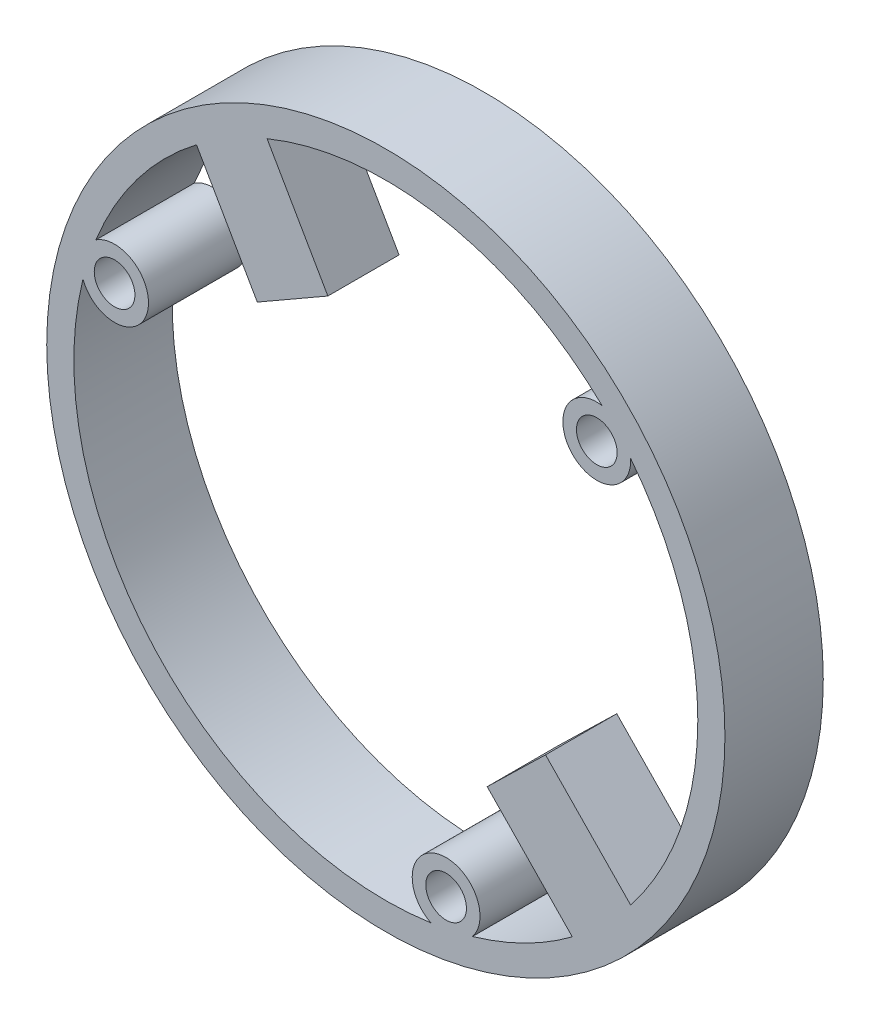
from build123d import *

# Parameters (mm, degrees)
SKETCH1_R             = 25
BOSS_EXTRUDE1_DEPTH   = 7.25
F_3_0MM_DOWEL_HOLE1_D = 3
CIRPATTERN1_COUNT     = 3
CUT_EXTRUDE7_DEPTH    = 8.25
CUT_EXTRUDE9_DEPTH    = 2


with BuildPart() as part:
    # Sketch1 → Boss-Extrude1 (new body)
    with BuildSketch(Plane.XY):
        Circle(SKETCH1_R)
    extrude(amount=BOSS_EXTRUDE1_DEPTH)

    # Ø3.0mm Dowel Hole1 (through all)
    with Locations(Plane(origin=(0, 0, 0), x_dir=(-1, 0, 0), z_dir=(0, 0, -1))):
        with Locations((-15.552844037, 14.110600354)):
            f_3_0mm_dowel_hole1 = Hole(F_3_0MM_DOWEL_HOLE1_D / 2)

    # CirPattern1: Ø3.0mm Dowel Hole1 ×3 about axis
    cirpattern1_axis = Axis((0, 0, 0), (0, 0, 1))
    for i in range(1, CIRPATTERN1_COUNT):
        add(f_3_0mm_dowel_hole1.rotate(cirpattern1_axis, i * 360 / CIRPATTERN1_COUNT), mode=Mode.SUBTRACT)

    # Sketch4 → Cut-Extrude7 (cut, through all)
    with BuildSketch(Plane(origin=(0, 0, 0), x_dir=(-1, 0, 0), z_dir=(0, 0, -1))):
        with BuildLine():
            Line((8.755064083, 21.268494373), (4.272899712, 13.463995507))
            Line((4.272899712, 13.463995507), (9.475898956, 10.475885926))
            Line((9.475898956, 10.475885926), (13.958063327, 18.280384792))
            ThreePointArc((13.958063327, 18.280384792), (18.328536057, 13.894774774), (21.370809866, 8.502263561))
            ThreePointArc((21.370809866, 8.502263561), (17.616017485, 5.650303353), (22.329156288, 5.514415606))
            ThreePointArc((22.329156288, 5.514415606), (17.034067279, -15.454467055), (-3.3222287, -22.758796024))
            ThreePointArc((-3.3222287, -22.758796024), (-3.9147025, -18.081070332), (-6.388954142, -22.094824393))
            ThreePointArc((-6.388954142, -22.094824393), (-10.232582573, -20.598404159), (-13.747128962, -18.439534845))
            Line((-13.747128962, -18.439534845), (-7.472625388, -11.987356538))
            Line((-7.472625388, -11.987356538), (-11.774077593, -7.804354156))
            Line((-11.774077593, -7.804354156), (-18.048581167, -14.256532463))
            ThreePointArc((-18.048581167, -14.256532463), (-23, 0), (-18.048581167, 14.256532463))
            ThreePointArc((-18.048581167, 14.256532463), (-13.701314985, 12.430766979), (-15.940202146, 16.580408787))
            ThreePointArc((-15.940202146, 16.580408787), (-4.289649037, 22.596435806), (8.755064083, 21.268494373))
        make_face()
    extrude(amount=-CUT_EXTRUDE7_DEPTH, mode=Mode.SUBTRACT)

    # Sketch9 → Cut-Extrude9 (cut)
    with BuildSketch(Plane(origin=(0, 0, 0), x_dir=(-1, 0, 0), z_dir=(0, 0, -1))):
        Polygon((-11.774077593, -7.804354156), (-18.048581167, -14.256532463), (-13.747128962, -18.439534845), (-7.472625388, -11.987356538), align=None)
        Polygon((4.272899712, 13.463995507), (8.755064083, 21.268494373), (13.958063327, 18.280384792), (9.475898956, 10.475885926), align=None)
    extrude(amount=-CUT_EXTRUDE9_DEPTH, mode=Mode.SUBTRACT)


solid = part.part
